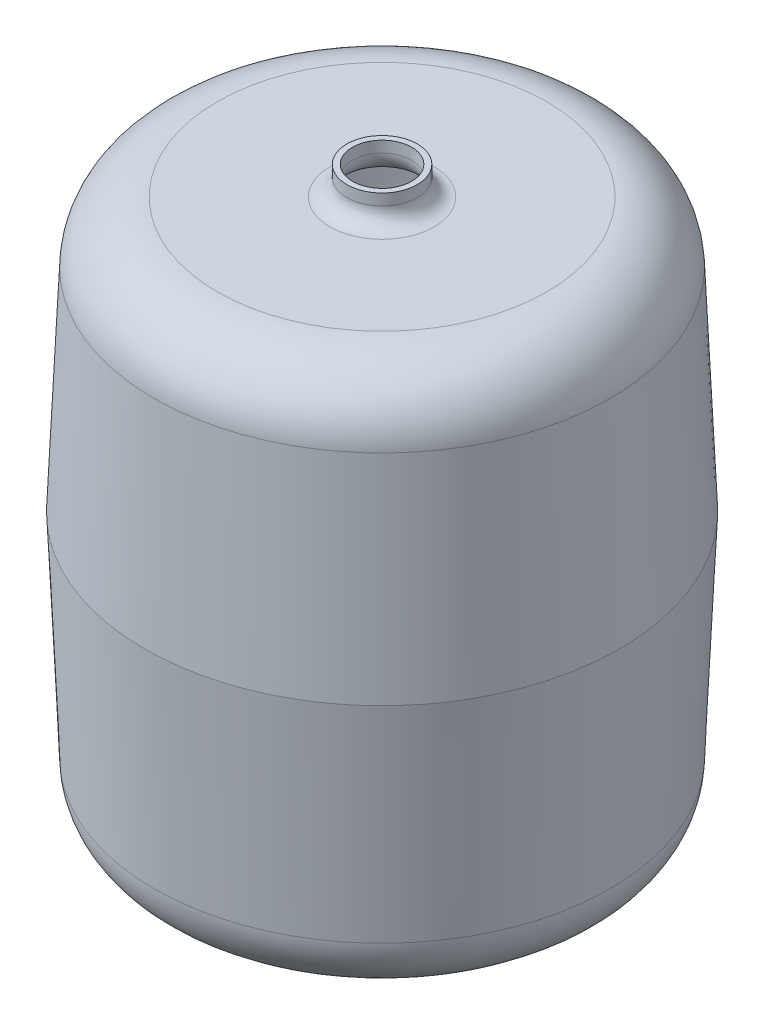
from build123d import *

# Parameters (mm, degrees)
SKETCH3_R          = 21
CUT_EXTRUDE1_DEPTH = 30


with BuildPart() as part:
    # Sketch1 → Revolve1 (revolve)
    with BuildSketch(Plane.XY):
        with BuildLine():
            Line((0, 0), (116.921871599, 0))
            ThreePointArc((116.921871599, 0), (148.039959109, 12.493621707), (161.87904157, 43.037127569))
            Line((161.87904157, 43.037127569), (168.459307689, 193.75))
            Line((168.459307689, 193.75), (161.87904157, 344.462872431))
            ThreePointArc((161.87904157, 344.462872431), (148.039959109, 375.006378293), (116.921871599, 387.5))
            Line((116.921871599, 387.5), (37, 387.5))
            ThreePointArc((37, 387.5), (28.514718626, 391.014718626), (25, 399.5))
            Line((25, 399.5), (25, 407.5))
            Line((25, 407.5), (0, 407.5))
            Line((0, 407.5), (0, 403.5))
            Line((0, 403.5), (21, 403.5))
            Line((21, 403.5), (21, 399.5))
            ThreePointArc((21, 399.5), (25.686291501, 388.186291501), (37, 383.5))
            Line((37, 383.5), (116.921871599, 383.5))
            ThreePointArc((116.921871599, 383.5), (145.273906886, 372.116922444), (157.882848683, 344.288394882))
            Line((157.882848683, 344.288394882), (164.455496948, 193.75))
            Line((164.455496948, 193.75), (157.882848683, 43.211605118))
            ThreePointArc((157.882848683, 43.211605118), (145.273906886, 15.383077556), (116.921871599, 4))
            Line((116.921871599, 4), (0, 4))
            Line((0, 4), (0, 0))
        make_face()
    revolve(axis=Axis((0, 579.019102, 0), (0, -1, 0)))

    # Sketch3 → Cut-Extrude1 (cut)
    with BuildSketch(Plane(origin=(0, 407.5, 0), x_dir=(1, 0, 0), z_dir=(0, 1, 0))):
        Circle(SKETCH3_R)
    extrude(amount=-CUT_EXTRUDE1_DEPTH, mode=Mode.SUBTRACT)


solid = part.part
